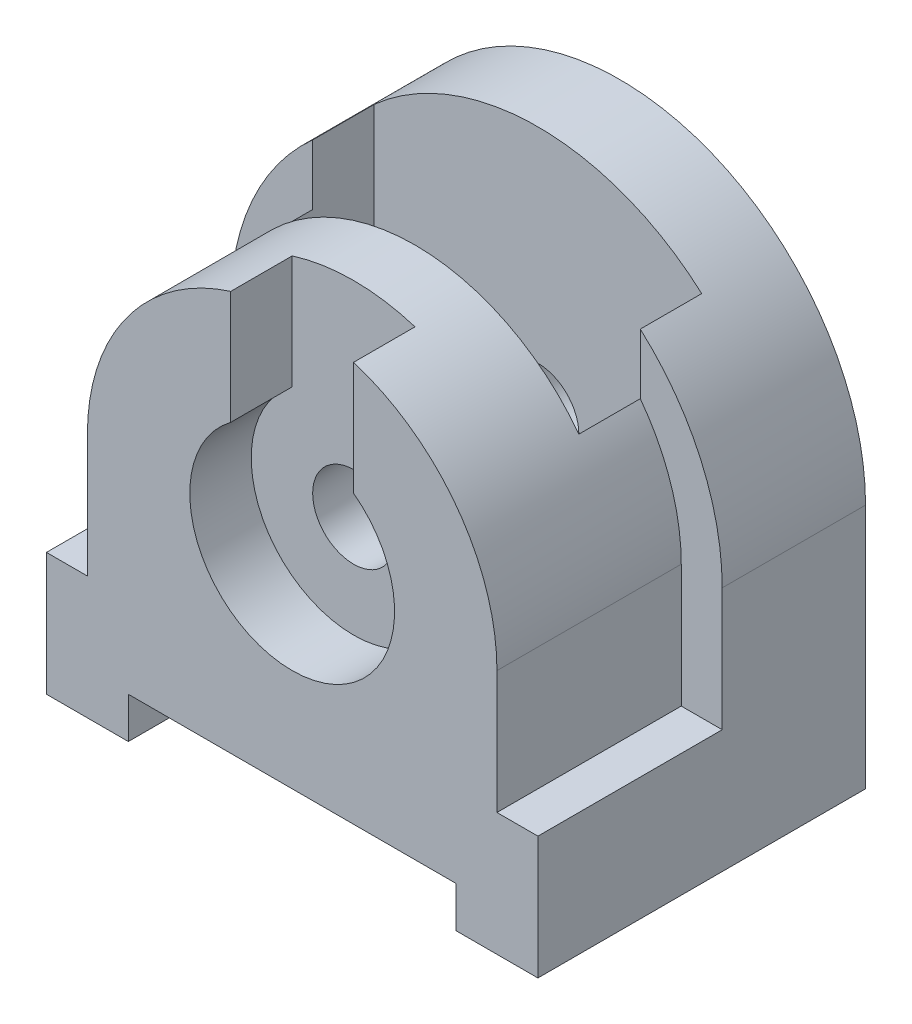
from build123d import *

# Parameters (mm, degrees)
SKETCH1_W           = 120
SKETCH1_H           = 60
BOSS_EXTRUDE2_DEPTH = 80
SKETCH2_W           = 80
SKETCH2_H           = 10
CUT_EXTRUDE1_DEPTH  = 80
BOSS_EXTRUDE3_DEPTH = 80
SKETCH4_R           = 10
CUT_EXTRUDE2_DEPTH  = 80
CUT_EXTRUDE3_DEPTH  = 15
CUT_EXTRUDE4_DEPTH  = 45
CUT_EXTRUDE5_DEPTH  = 30
SKETCH13_W          = 80
SKETCH13_H          = 30
CUT_EXTRUDE12_DEPTH = 950
SKETCH14_W          = 10
SKETCH14_H          = 25
BOSS_EXTRUDE4_DEPTH = 30


with BuildPart() as part:
    # Sketch1 → Boss-Extrude2 (new body)
    with BuildSketch(Plane.XY):
        with Locations((60, 30)):
            Rectangle(SKETCH1_W, SKETCH1_H)
    extrude(amount=BOSS_EXTRUDE2_DEPTH)

    # Sketch2 → Cut-Extrude1 (cut)
    with BuildSketch(Plane.XY.offset(80)):
        with Locations((60, 5)):
            Rectangle(SKETCH2_W, SKETCH2_H)
    extrude(amount=-CUT_EXTRUDE1_DEPTH, mode=Mode.SUBTRACT)

    # Sketch3 → Boss-Extrude3 (add)
    with BuildSketch(Plane.XY.offset(80)):
        with BuildLine():
            Line((0, 60), (120, 60))
            ThreePointArc((120, 60), (60, 120), (0, 60))
        make_face()
    extrude(amount=-BOSS_EXTRUDE3_DEPTH)

    # Sketch4 → Cut-Extrude2 (cut)
    with BuildSketch(Plane.XY.offset(80)):
        with Locations((60, 60)):
            Circle(SKETCH4_R)
    extrude(amount=-CUT_EXTRUDE2_DEPTH, mode=Mode.SUBTRACT)

    # Sketch5 → Cut-Extrude3 (cut)
    with BuildSketch(Plane.XY.offset(80)):
        with BuildLine():
            Line((45, 80), (45, 118.094750193))
            ThreePointArc((45, 118.094750193), (60, 120.1113283), (75, 118.094750193))
            Line((75, 118.094750193), (75, 80))
            ThreePointArc((75, 80), (60, 35), (45, 80))
        make_face()
    extrude(amount=-CUT_EXTRUDE3_DEPTH, mode=Mode.SUBTRACT)

    # Sketch6 → Cut-Extrude4 (cut)
    with BuildSketch(Plane.XY.offset(80)):
        with BuildLine():
            Line((10, 30), (10, 60))
            ThreePointArc((10, 60), (12.565835097, 75.811388301), (20, 90))
            Line((20, 90), (20, 104.72135955))
            ThreePointArc((20, 104.72135955), (5.227744249, 84.494897428), (0, 60))
            Line((0, 60), (0, 30))
            Line((0, 30), (10, 30))
        make_face()
        with BuildLine():
            Line((100, 104.72135955), (100, 90))
            ThreePointArc((100, 90), (107.434164903, 75.811388301), (110, 60))
            Line((110, 60), (110, 30))
            Line((110, 30), (120, 30))
            Line((120, 30), (120, 60))
            ThreePointArc((120, 60), (114.772255751, 84.494897428), (100, 104.72135955))
        make_face()
    extrude(amount=-CUT_EXTRUDE4_DEPTH, mode=Mode.SUBTRACT)

    # Sketch7 → Cut-Extrude5 (cut)
    with BuildSketch(Plane.XY.offset(80)):
        with BuildLine():
            Line((0, 60), (10, 60))
            ThreePointArc((10, 60), (60, 110), (110, 60))
            Line((110, 60), (120, 60))
            ThreePointArc((120, 60), (60, 120), (0, 60))
        make_face()
    extrude(amount=-CUT_EXTRUDE5_DEPTH, mode=Mode.SUBTRACT)

    # Sketch13 → Cut-Extrude12 (cut)
    with BuildSketch(Plane(origin=(0, 10, 0), x_dir=(-1, 0, 0), z_dir=(0, -1, 0))):
        with Locations((-60, -35)):
            Rectangle(SKETCH13_W, SKETCH13_H)
    extrude(amount=-CUT_EXTRUDE12_DEPTH, mode=Mode.SUBTRACT)

    # Sketch14 → Boss-Extrude4 (add)
    with BuildSketch(Plane.XY.offset(20)):
        with Locations((60, 22.5)):
            Rectangle(SKETCH14_W, SKETCH14_H)
    extrude(amount=BOSS_EXTRUDE4_DEPTH)


solid = part.part
